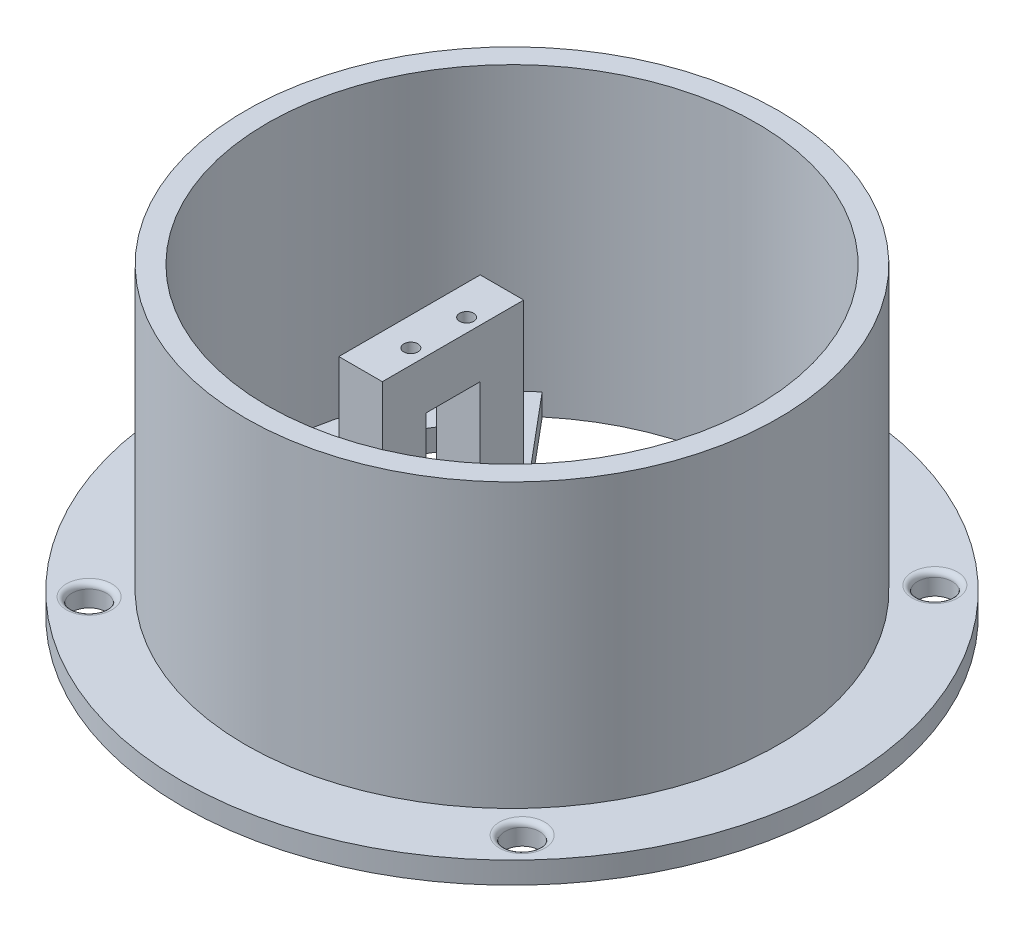
from build123d import *

# Parameters (mm, degrees)
SALIENTE_EXTRUIR2_DEPTH = 4
CROQUIS4_W              = 8
CROQUIS4_H              = 26
SALIENTE_EXTRUIR4_DEPTH = 34
CORTAR_EXTRUIR1_REACH   = 35.75
CROQUIS5_W              = 10
CROQUIS5_H              = 24
CROQUIS6_R              = 1.3
CORTAR_EXTRUIR2_DEPTH   = 7
SALIENTE_EXTRUIR5_DEPTH = 38
CROQUIS10_R             = 49
CROQUIS10_R_2           = 45
SALIENTE_EXTRUIR6_DEPTH = 56
CORTAR_EXTRUIR3_DEPTH   = 38
CROQUIS12_R             = 60.625
CROQUIS12_R_2           = 49
SALIENTE_EXTRUIR8_DEPTH = 4
CROQUIS13_R             = 3.1645
CORTAR_EXTRUIR5_DEPTH   = 14
CROQUIS14_R             = 1.3
CORTAR_EXTRUIR6_DEPTH   = 5
REDONDEO1_R             = 1


with BuildPart() as part:
    # Croquis1 → Saliente-Extruir2 (new body)
    with BuildSketch(Plane(origin=(0, 0, 0), x_dir=(1, 0, 0), z_dir=(0, 1, 0))):
        with BuildLine():
            Line((-11.25, 13.407227917), (-11.25, -12.592772083))
            Line((-11.25, -12.592772083), (-29.32452611, -34.133153509))
            ThreePointArc((-29.32452611, -34.133153509), (-44.999238647, 0.261765488), (-28.925442436, 34.47199994))
            Line((-28.925442436, 34.47199994), (-11.25, 13.407227917))
        make_face()
    extrude(amount=SALIENTE_EXTRUIR2_DEPTH)

    # Croquis4 → Saliente-Extruir4 (add)
    with BuildSketch(Plane(origin=(0, 4, 0), x_dir=(1, 0, 0), z_dir=(0, 1, 0))):
        with Locations((-15.25, 0.407227917)):
            Rectangle(CROQUIS4_W, CROQUIS4_H)
    extrude(amount=SALIENTE_EXTRUIR4_DEPTH)

    # Croquis5 → Cortar-Extruir1 (cut, up to next)
    with BuildSketch(Plane(origin=(-11.25, 0, 0), x_dir=(0, 0, -1), z_dir=(1, 0, 0)), mode=Mode.PRIVATE) as cortar_extruir1_sk1:
        with Locations((0.407227917, 17)):
            Rectangle(CROQUIS5_W, CROQUIS5_H)
    cortar_extruir1_tool1 = extrude(cortar_extruir1_sk1.sketch, amount=-CORTAR_EXTRUIR1_REACH, mode=Mode.PRIVATE) & part.part
    add(cortar_extruir1_tool1.solids().sort_by_distance((-11.25, 17, -0.407228))[0], mode=Mode.SUBTRACT)

    # Croquis6 → Cortar-Extruir2 (cut)
    with BuildSketch(Plane(origin=(0, 38, 0), x_dir=(1, 0, 0), z_dir=(0, 1, 0))):
        with Locations((-13.75, 5.407227917)):
            Circle(CROQUIS6_R)
        with Locations((-14.009261416, -4.592772083)):
            Circle(CROQUIS6_R)
    extrude(amount=-CORTAR_EXTRUIR2_DEPTH, mode=Mode.SUBTRACT)



with BuildPart() as body_2:
    # Croquis8 → Saliente-Extruir5 (new body)
    with BuildSketch(Plane(origin=(0, 0, 0), x_dir=(1, 0, 0), z_dir=(0, 1, 0))):
        with BuildLine():
            Line((31.75, 13.407227917), (31.75, -12.617796762))
            Line((31.75, -12.617796762), (43.287959819, -12.617796762))
            ThreePointArc((43.287959819, -12.617796762), (45.08754045, 0.412257936), (43.05, 13.407227917))
            Line((43.05, 13.407227917), (31.75, 13.407227917))
        make_face()
    extrude(amount=SALIENTE_EXTRUIR5_DEPTH)


with BuildPart() as part_1:
    add(part.part)

    add(body_2.part)  # Saliente-Extruir6 merges body 2
    # Croquis10 → Saliente-Extruir6 (add)
    with BuildSketch(Plane(origin=(0, 0, 0), x_dir=(1, 0, 0), z_dir=(0, 1, 0))):
        Circle(CROQUIS10_R)
        Circle(CROQUIS10_R_2, mode=Mode.SUBTRACT)
    extrude(amount=SALIENTE_EXTRUIR6_DEPTH)

    # Croquis11 → Cortar-Extruir3 (cut)
    with BuildSketch(Plane(origin=(0, 4, 0), x_dir=(1, 0, 0), z_dir=(0, 1, 0))):
        with BuildLine():
            Line((-24.25, 17.136853161), (-24.25, -15.043146839))
            Line((-24.25, -15.043146839), (-29.477670597, -21.308692316))
            ThreePointArc((-29.477670597, -21.308692316), (-38.734718404, 1.046853161), (-29.477670597, 23.402398638))
            Line((-29.477670597, 23.402398638), (-24.25, 17.136853161))
        make_face()
    extrude(amount=-CORTAR_EXTRUIR3_DEPTH, mode=Mode.SUBTRACT)

    # Croquis12 → Saliente-Extruir8 (add)
    with BuildSketch(Plane(origin=(0, 0, 0), x_dir=(1, 0, 0), z_dir=(0, 1, 0))):
        Circle(CROQUIS12_R)
        Circle(CROQUIS12_R_2, mode=Mode.SUBTRACT)
    extrude(amount=SALIENTE_EXTRUIR8_DEPTH)

    # Croquis13 → Cortar-Extruir5 (cut)
    with BuildSketch(Plane(origin=(0, 0, 0), x_dir=(1, 0, 0), z_dir=(0, 1, 0))):
        with Locations((-39.815475686, 37.946645437)):
            Circle(CROQUIS13_R)
        with Locations((37.944524314, 39.81473439)):
            Circle(CROQUIS13_R)
        with Locations((39.814027902, -37.94526561)):
            Circle(CROQUIS13_R)
        with Locations((-37.945972098, -39.813354563)):
            Circle(CROQUIS13_R)
    extrude(amount=CORTAR_EXTRUIR5_DEPTH, mode=Mode.SUBTRACT)

    # Croquis14 → Cortar-Extruir6 (cut)
    with BuildSketch(Plane(origin=(0, 38, 0), x_dir=(1, 0, 0), z_dir=(0, 1, 0))):
        with Locations((34.25, 5.407227917)):
            Circle(CROQUIS14_R)
        with Locations((34.25, -4.617796762)):
            Circle(CROQUIS14_R)
    extrude(amount=-CORTAR_EXTRUIR6_DEPTH, mode=Mode.SUBTRACT)

    # Redondeo1
    redondeo1_edges = [part_1.edges().sort_by_distance(p)[0] for p in [
        (-41.110472098, 4, 39.813354563),
        (36.649527902, 4, 37.94526561),
        (34.780024314, 4, -39.81473439),
        (-42.979975686, 4, -37.946645437),
    ]]
    fillet(redondeo1_edges, radius=REDONDEO1_R)


solid = part_1.part
